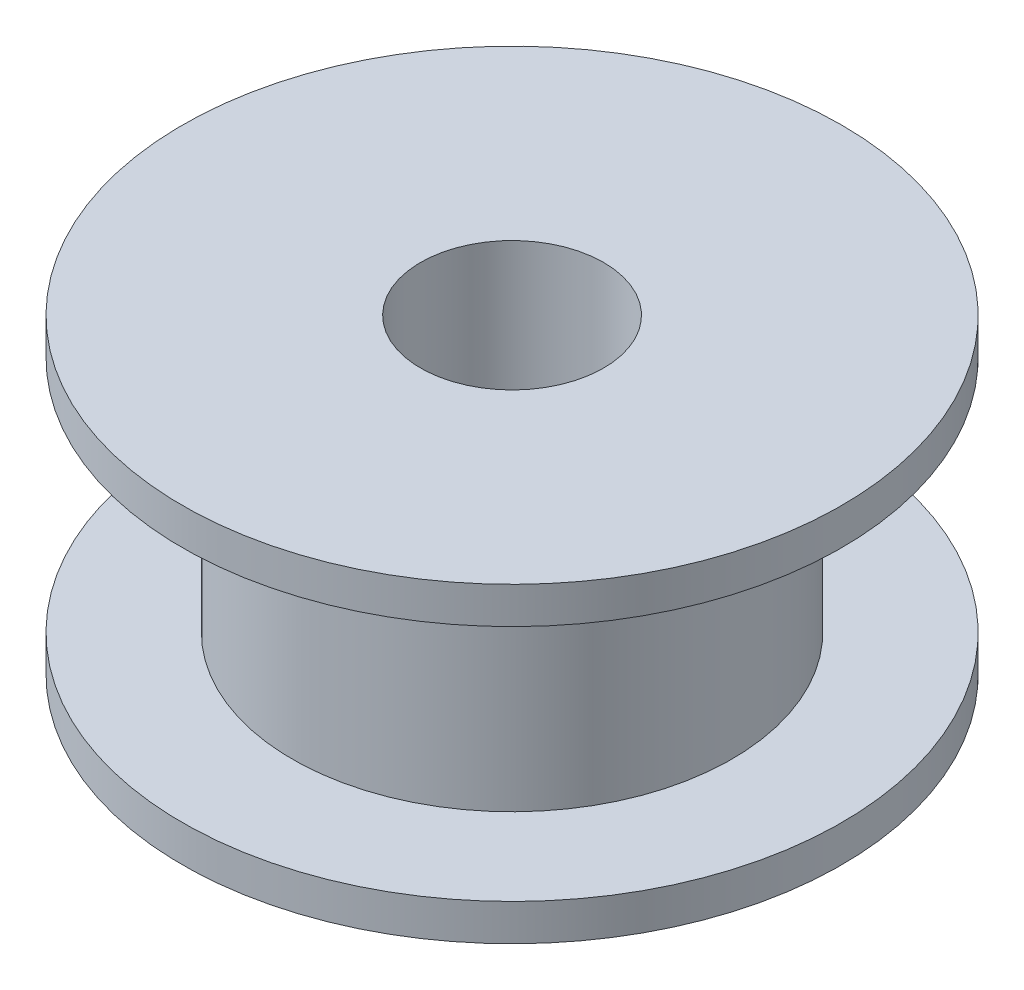
from build123d import *


with BuildPart() as part:
    # Esquisse1 → Révolution1 (revolve)
    with BuildSketch(Plane.XY):
        Polygon((-6, 7.5), (-6, 1), (-9, 1), (-9, 0), (-6, 0), (-2.5, 0), (-2.5, 8.5), (-6, 8.5), (-9, 8.5), (-9, 7.5), align=None)
    revolve(axis=Axis((0, 0, 0), (0, 1, 0)))


solid = part.part
